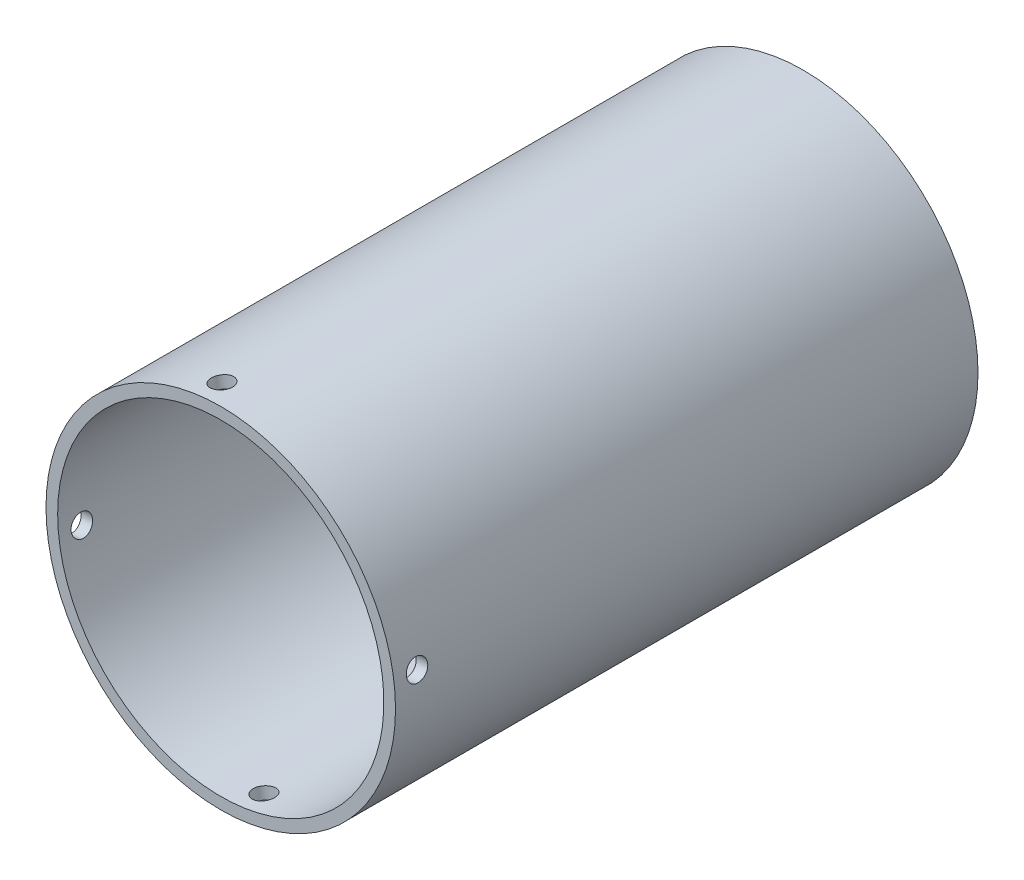
from build123d import *

# Parameters (mm, degrees)
ESQUISSE1_R                  = 45
BOSS_EXTRU_1_DEPTH           = 150
ESQUISSE2_R                  = 42
ENL_V_MAT_EXTRU_1_DEPTH      = 150
D_GAGEMENT_M51_D             = 5.5
R_P_TITION_CIRCULAIRE1_COUNT = 2
R_P_TITION_CIRCULAIRE1_ANGLE = 90


with BuildPart() as part:
    # Esquisse1 → Boss.-Extru.1 (new body)
    with BuildSketch(Plane.XY):
        Circle(ESQUISSE1_R)
    extrude(amount=BOSS_EXTRU_1_DEPTH)

    # Esquisse2 → Enlèv. mat.-Extru.1 (cut)
    with BuildSketch(Plane(origin=(0, 0, 0), x_dir=(-1, 0, 0), z_dir=(0, 0, -1))):
        Circle(ESQUISSE2_R)
    extrude(amount=-ENL_V_MAT_EXTRU_1_DEPTH, mode=Mode.SUBTRACT)

    # Dégagement M51 (through all)
    with Locations(Plane(origin=(-44.649010523, -5.609443765, 144.107816194), x_dir=(0.124654306, -0.992200234, 0), z_dir=(-0.992200234, -0.124654306, 0))):
        with Locations((0, 0)):
            d_gagement_m51 = Hole(D_GAGEMENT_M51_D / 2)

    # Répétition circulaire1: Dégagement M51 ×2 about axis
    r_p_tition_circulaire1_axis = Axis((0, 0, 0), (0, 0, 1))
    for i in range(1, R_P_TITION_CIRCULAIRE1_COUNT):
        add(d_gagement_m51.rotate(r_p_tition_circulaire1_axis, i * R_P_TITION_CIRCULAIRE1_ANGLE / (R_P_TITION_CIRCULAIRE1_COUNT - 1)), mode=Mode.SUBTRACT)


solid = part.part
